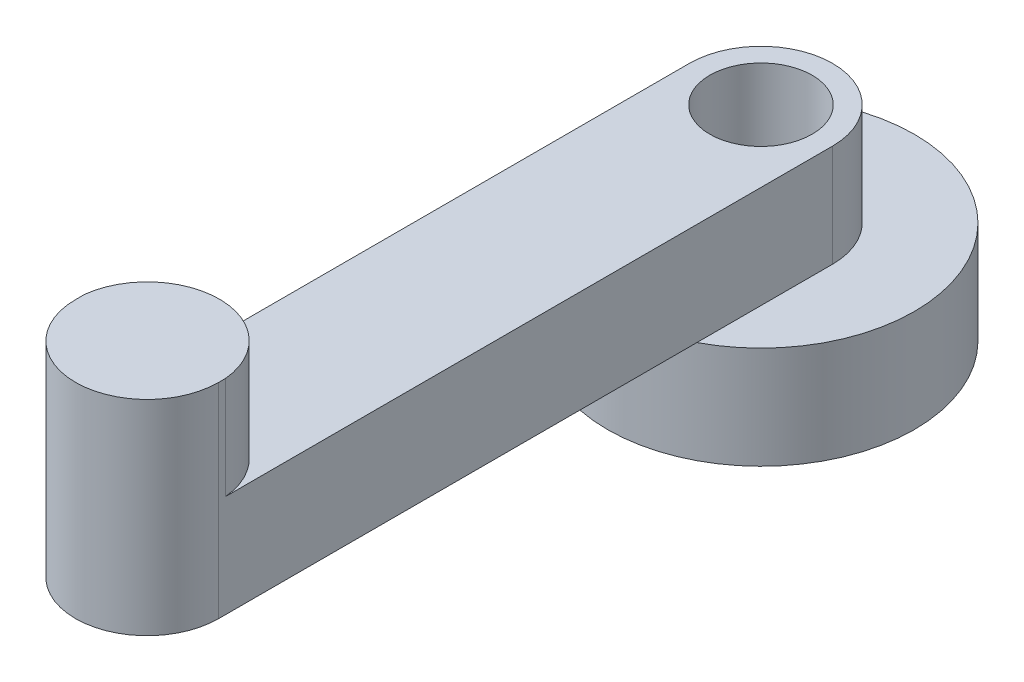
from build123d import *

# Parameters (mm, degrees)
SKETCH1_R           = 75
BOSS_EXTRUDE1_DEPTH = 50
BOSS_EXTRUDE2_DEPTH = 50
BOSS_EXTRUDE3_DEPTH = 50
SKETCH4_R           = 25
CUT_EXTRUDE1_DEPTH  = 151


with BuildPart() as part:
    # Sketch1 → Boss-Extrude1 (new body)
    with BuildSketch(Plane(origin=(0, 0, 0), x_dir=(1, 0, 0), z_dir=(0, 1, 0))):
        Circle(SKETCH1_R)
    extrude(amount=BOSS_EXTRUDE1_DEPTH)

    # Sketch2 → Boss-Extrude2 (add)
    with BuildSketch(Plane(origin=(0, 50, 0), x_dir=(1, 0, 0), z_dir=(0, 1, 0))):
        with BuildLine():
            Line((-35, 0), (-35, -300))
            ThreePointArc((-35, -300), (0, -335), (35, -300))
            Line((35, -300), (35, 0))
            ThreePointArc((35, 0), (0, 35), (-35, 0))
        make_face()
    extrude(amount=BOSS_EXTRUDE2_DEPTH)

    # Sketch3 → Boss-Extrude3 (add)
    with BuildSketch(Plane(origin=(0, 100, 0), x_dir=(1, 0, 0), z_dir=(0, 1, 0))):
        with BuildLine():
            ThreePointArc((11.953887913, -332.895357784), (28.366317111, -320.502488959), (34.9848173, -301.03080477))
            ThreePointArc((34.9848173, -301.03080477), (34.996204119, -300.515458289), (35, -300))
            Line((35, -300), (35, -296.670788492))
            ThreePointArc((35, -296.670788492), (0.598184033, -264.595673491), (-35, -295.33761939))
            Line((-35, -295.33761939), (-35, -300))
            ThreePointArc((-35, -300), (-20.082503866, -328.665188617), (11.953887913, -332.895357784))
        make_face()
    extrude(amount=BOSS_EXTRUDE3_DEPTH)

    # Sketch4 → Cut-Extrude1 (cut, through all)
    with BuildSketch(Plane.XZ):
        Circle(SKETCH4_R)
    extrude(amount=-CUT_EXTRUDE1_DEPTH, mode=Mode.SUBTRACT)


solid = part.part
